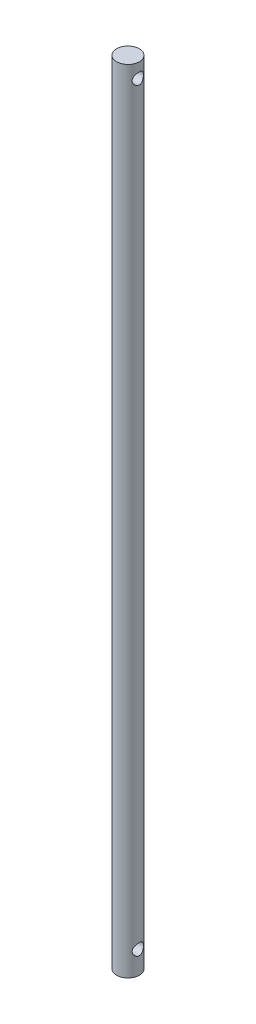
from build123d import *

# Parameters (mm, degrees)
SKETCH1_R           = 5
SKETCH1_R_2         = 4.5
BOSS_EXTRUDE1_DEPTH = 350
SKETCH2_R           = 5
BOSS_EXTRUDE2_DEPTH = 30
SKETCH3_R           = 5
BOSS_EXTRUDE4_DEPTH = 30
SKETCH4_R           = 2.5
CUT_EXTRUDE1_DEPTH  = 15
SKETCH5_R           = 2.5
CUT_EXTRUDE2_DEPTH  = 15


with BuildPart() as part:
    # Sketch1 → Boss-Extrude1 (new body)
    with BuildSketch(Plane(origin=(0, 0, 0), x_dir=(1, 0, 0), z_dir=(0, 1, 0))):
        Circle(SKETCH1_R)
        Circle(SKETCH1_R_2, mode=Mode.SUBTRACT)
    extrude(amount=BOSS_EXTRUDE1_DEPTH)

    # Sketch2 → Boss-Extrude2 (add)
    with BuildSketch(Plane(origin=(0, 350, 0), x_dir=(1, 0, 0), z_dir=(0, 1, 0))):
        Circle(SKETCH2_R)
    extrude(amount=-BOSS_EXTRUDE2_DEPTH)

    # Sketch3 → Boss-Extrude4 (add)
    with BuildSketch(Plane(origin=(0, 0, 0), x_dir=(-1, 0, 0), z_dir=(0, -1, 0))):
        Circle(SKETCH3_R)
    extrude(amount=-BOSS_EXTRUDE4_DEPTH)

    # Sketch4 → Cut-Extrude1 (cut, symmetric)
    with BuildSketch(Plane(origin=(0, 0, 0), x_dir=(0, 0, -1), z_dir=(1, 0, 0))):
        with Locations((0, 10)):
            Circle(SKETCH4_R)
    extrude(amount=CUT_EXTRUDE1_DEPTH, both=True, mode=Mode.SUBTRACT)

    # Sketch5 → Cut-Extrude2 (cut, symmetric)
    with BuildSketch(Plane(origin=(0, 0, 0), x_dir=(0, 0, -1), z_dir=(1, 0, 0))):
        with Locations((0, 343.604340323)):
            Circle(SKETCH5_R)
    extrude(amount=CUT_EXTRUDE2_DEPTH, both=True, mode=Mode.SUBTRACT)


solid = part.part
